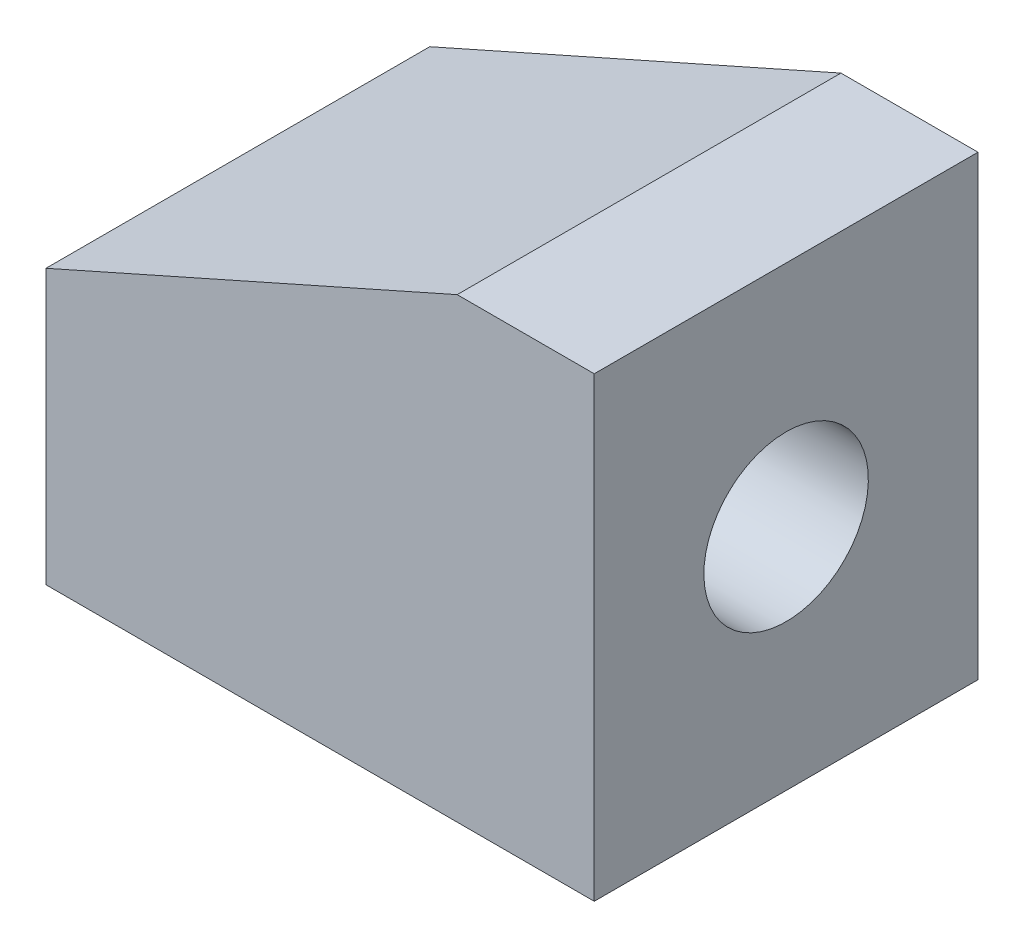
from build123d import *

# Parameters (mm, degrees)
BOSS_EXTRUDE1_DEPTH = 42
SKETCH2_R           = 9
CUT_EXTRUDE1_DEPTH  = 40


with BuildPart() as part:
    # Sketch1 → Boss-Extrude1 (new body)
    with BuildSketch(Plane.XY):
        Polygon((-38.235294118, -17.058823529), (21.764705882, -17.058823529), (21.764705882, 32.941176471), (6.764705882, 32.941176471), (-38.235294118, 12.941176471), align=None)
    extrude(amount=BOSS_EXTRUDE1_DEPTH)

    # Sketch2 → Cut-Extrude1 (cut)
    with BuildSketch(Plane(origin=(21.764705882, 0, 0), x_dir=(0, 0, -1), z_dir=(1, 0, 0))):
        with Locations((-21, 7.941176471)):
            Circle(SKETCH2_R)
    extrude(amount=-CUT_EXTRUDE1_DEPTH, mode=Mode.SUBTRACT)


solid = part.part
